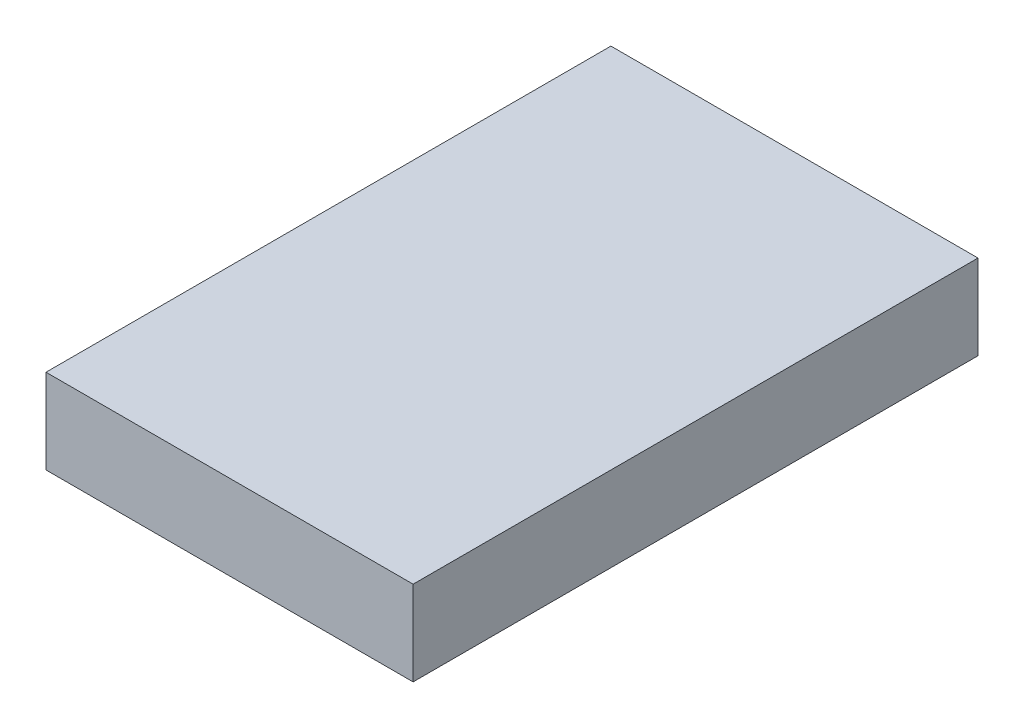
from build123d import *

# Parameters (mm, degrees)
SKIZZE1_W                       = 6.4986
SKIZZE1_H                       = 1.4986
AUFSATZ_LINEAR_AUSTRAGEN1_DEPTH = 10


with BuildPart() as part:
    # Skizze1 → Aufsatz-Linear austragen1 (new body)
    with BuildSketch(Plane.XY):
        with Locations((211.2, -20.8)):
            Rectangle(SKIZZE1_W, SKIZZE1_H)
    extrude(amount=AUFSATZ_LINEAR_AUSTRAGEN1_DEPTH)


solid = part.part
